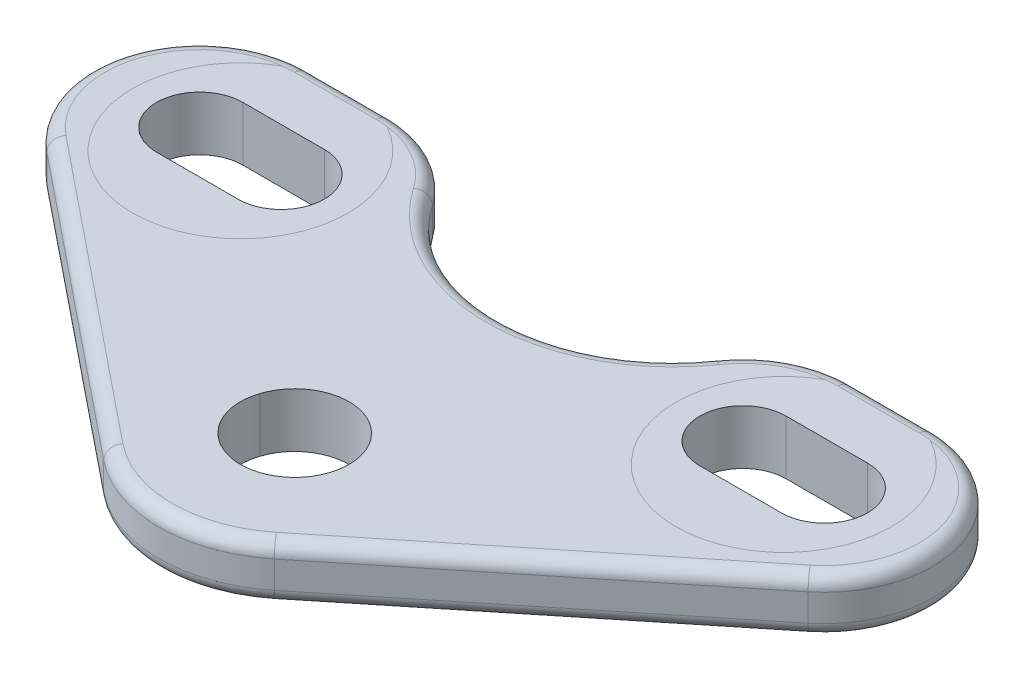
from build123d import *

# Parameters (mm, degrees)
SKETCH1_R           = 4
BOSS_EXTRUDE1_DEPTH = 4
FILLET1_R           = 1


with BuildPart() as part:
    # Sketch1 → Boss-Extrude1 (new body)
    with BuildSketch(Plane(origin=(0, 0, 0), x_dir=(1, 0, 0), z_dir=(0, 1, 0))):
        with BuildLine():
            Line((-28.025651318, -6.22437377), (-6.282064148, -23.780467212))
            ThreePointArc((-6.282064148, -23.780467212), (0, -26), (6.282064148, -23.780467212))
            Line((6.282064148, -23.780467212), (28.025651318, -6.22437377))
            ThreePointArc((28.025651318, -6.22437377), (30.543042826, 2.665052517), (23, 8))
            Line((23, 8), (17, 8))
            ThreePointArc((17, 8), (13.292968107, 7.089281666), (10.429951691, 4.564478636))
            ThreePointArc((10.429951691, 4.564478636), (0, -0.88941153), (-10.429951691, 4.564478636))
            ThreePointArc((-10.429951691, 4.564478636), (-13.292968107, 7.089281666), (-17, 8))
            Line((-17, 8), (-23, 8))
            ThreePointArc((-23, 8), (-30.543042826, 2.665052517), (-28.025651318, -6.22437377))
        make_face()
        with Locations((0, -16)):
            Circle(SKETCH1_R, mode=Mode.SUBTRACT)
        with BuildLine():
            Line((-23, 3.175), (-17, 3.175))
            ThreePointArc((-17, 3.175), (-13.825, 0), (-17, -3.175))
            Line((-17, -3.175), (-23, -3.175))
            ThreePointArc((-23, -3.175), (-26.175, 0), (-23, 3.175))
        make_face(mode=Mode.SUBTRACT)
        with BuildLine():
            Line((17, 3.175), (23, 3.175))
            ThreePointArc((23, 3.175), (26.175, 0), (23, -3.175))
            Line((23, -3.175), (17, -3.175))
            ThreePointArc((17, -3.175), (13.825, 0), (17, 3.175))
        make_face(mode=Mode.SUBTRACT)
    extrude(amount=BOSS_EXTRUDE1_DEPTH)

    # Fillet1
    fillet1_edges = [part.edges().sort_by_distance(p)[0] for p in [
        (0, 4, 26),
        (0, 0, 0.88941153),
        (13.292968107, 0, -7.089281666),
        (20, 0, -8),
        (30.543042826, 0, -2.665052517),
        (17.153857733, 0, 15.002420491),
        (0, 0, 26),
        (-17.153857733, 0, 15.002420491),
        (-30.543042826, 0, -2.665052517),
        (17.153857733, 4, 15.002420491),
        (30.543042826, 4, -2.665052517),
        (20, 4, -8),
        (13.292968107, 4, -7.089281666),
        (0, 4, 0.88941153),
        (-13.292968107, 4, -7.089281666),
        (-20, 4, -8),
        (-30.543042826, 4, -2.665052517),
        (-17.153857733, 4, 15.002420491),
        (-20, 0, -8),
        (-13.292968107, 0, -7.089281666),
    ]]
    fillet(fillet1_edges, radius=FILLET1_R)


solid = part.part
